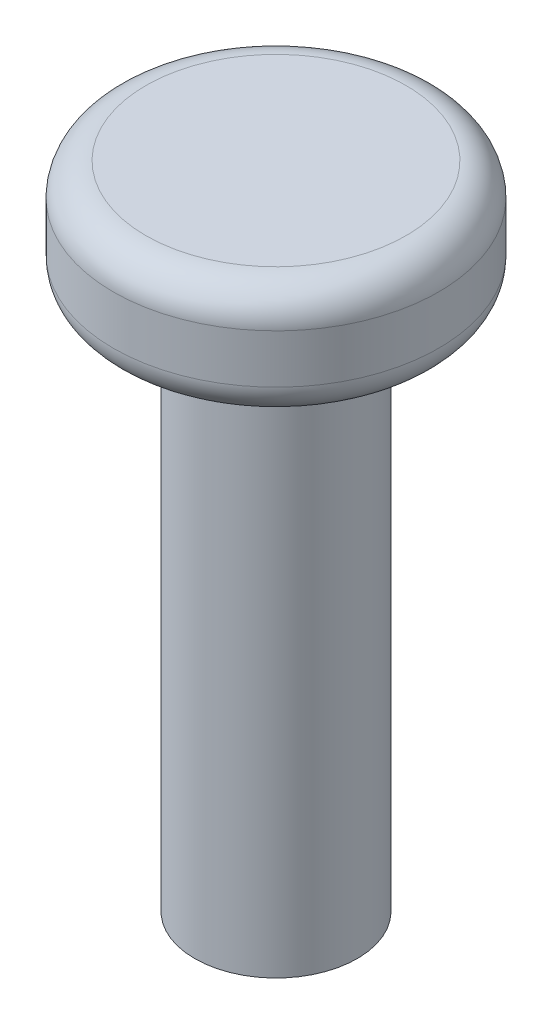
from build123d import *

# Parameters (mm, degrees)
SKETCH2_R           = 2.5
SKETCH2_W           = 2
SKETCH2_H           = 1.25
BOSS_EXTRUDE1_DEPTH = 10
FILLET1_R           = 1
SKETCH3_W           = 2
SKETCH3_H           = 1.25
BOSS_EXTRUDE5_DEPTH = 16
SKETCH4_R           = 5
THUMB_STICK_DEPTH   = 3.5
FILLET2_R           = 1
FILLET3_R           = 1


with BuildPart() as part:
    # Sketch2 → Boss-Extrude1 (new body, symmetric)
    with BuildSketch(Plane(origin=(0, 0, 0), x_dir=(1, 0, 0), z_dir=(0, 1, 0))):
        Circle(SKETCH2_R)
        Rectangle(SKETCH2_W, SKETCH2_H, mode=Mode.SUBTRACT)
    extrude(amount=BOSS_EXTRUDE1_DEPTH, both=True)

    # Fillet1
    fillet1_edges = [part.edges().sort_by_distance(p)[0] for p in [
        (-2.5, 10, 0),
    ]]
    fillet(fillet1_edges, radius=FILLET1_R)

    # Sketch3 → Boss-Extrude5 (add)
    with BuildSketch(Plane(origin=(0, 10, 0), x_dir=(1, 0, 0), z_dir=(0, 1, 0))):
        Rectangle(SKETCH3_W, SKETCH3_H)
    extrude(amount=-BOSS_EXTRUDE5_DEPTH)

    # Sketch4 → Thumb Stick (add)
    with BuildSketch(Plane(origin=(0, 10, 0), x_dir=(1, 0, 0), z_dir=(0, 1, 0))):
        Circle(SKETCH4_R)
    extrude(amount=-THUMB_STICK_DEPTH)

    # Fillet2
    fillet2_edges = [part.edges().sort_by_distance(p)[0] for p in [
        (-5, 6.5, 0),
    ]]
    fillet(fillet2_edges, radius=FILLET2_R)

    # Fillet3
    fillet3_edges = [part.edges().sort_by_distance(p)[0] for p in [
        (-5, 10, 0),
    ]]
    fillet(fillet3_edges, radius=FILLET3_R)


solid = part.part
